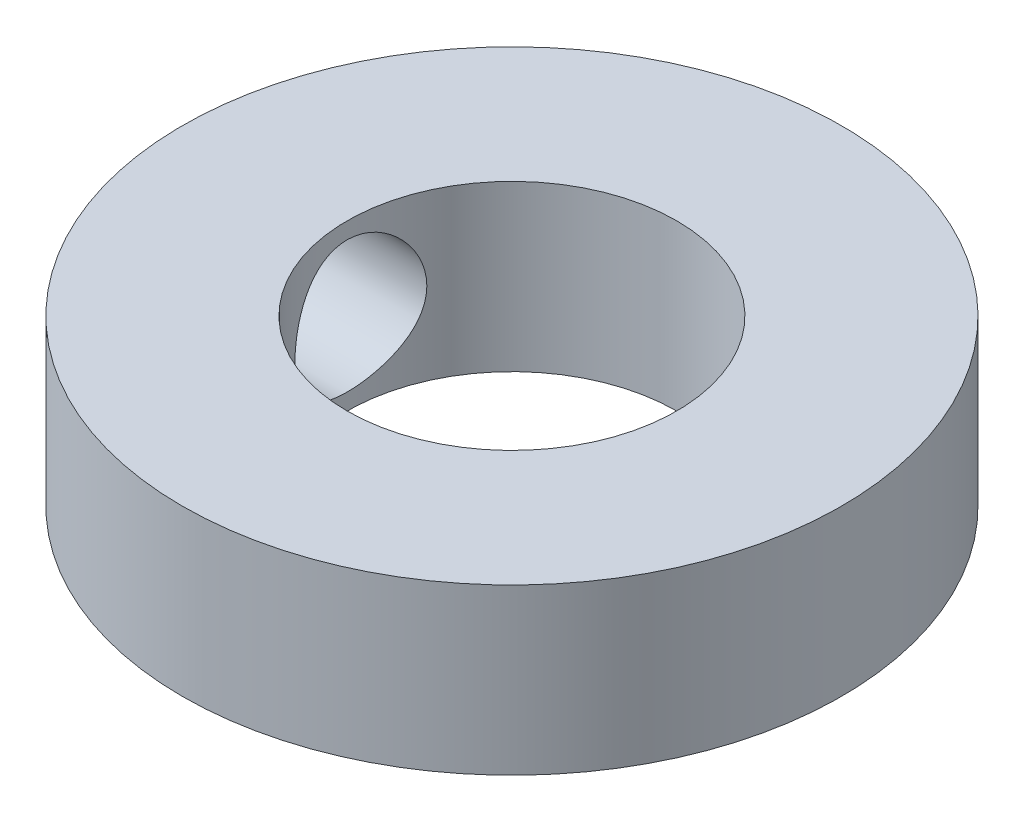
from build123d import *

# Parameters (mm, degrees)
SKETCH1_R           = 6.35
SKETCH1_R_2         = 3.175
BOSS_EXTRUDE1_DEPTH = 3.175
SKETCH2_R           = 1.27
CUT_EXTRUDE1_DEPTH  = 7.35


with BuildPart() as part:
    # Sketch1 → Boss-Extrude1 (new body)
    with BuildSketch(Plane(origin=(0, 0, 0), x_dir=(1, 0, 0), z_dir=(0, 1, 0))):
        Circle(SKETCH1_R)
        Circle(SKETCH1_R_2, mode=Mode.SUBTRACT)
    extrude(amount=BOSS_EXTRUDE1_DEPTH)

    # Sketch2 → Cut-Extrude1 (cut, through all)
    with BuildSketch(Plane(origin=(0, 0, 0), x_dir=(0, 0, -1), z_dir=(1, 0, 0))):
        with Locations((0, 1.5875)):
            Circle(SKETCH2_R)
    extrude(amount=-CUT_EXTRUDE1_DEPTH, mode=Mode.SUBTRACT)


solid = part.part
